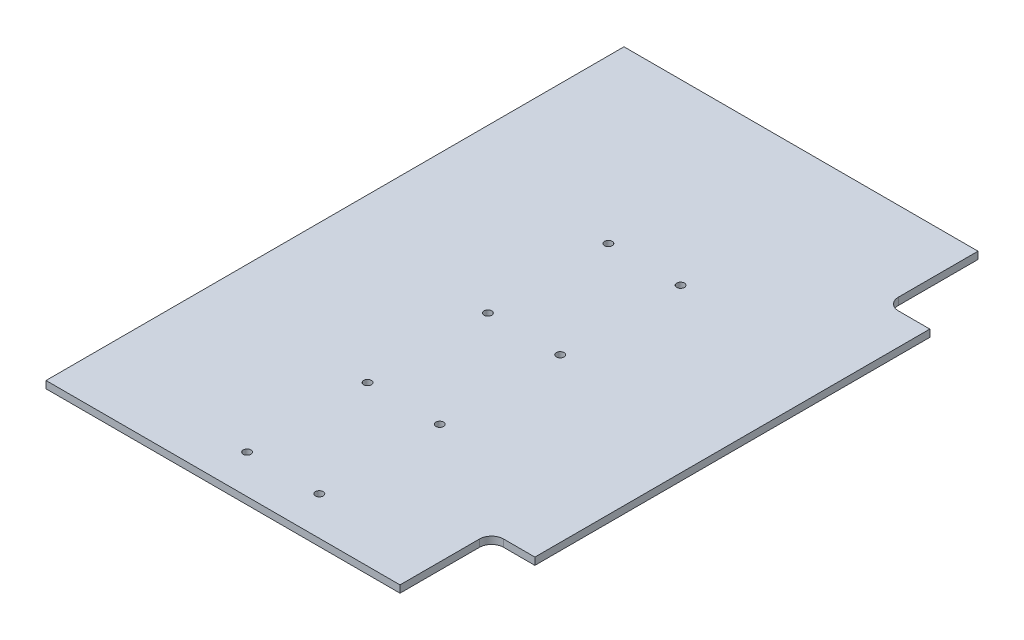
from build123d import *

# Parameters (mm, degrees)
SKETCH1_W           = 165
SKETCH1_H           = 240
BOSS_EXTRUDE1_DEPTH = 3
SKETCH3_R           = 1.6
CUT_EXTRUDE2_DEPTH  = 11
SKETCH2_W           = 18
SKETCH2_H           = 38
CUT_EXTRUDE1_DEPTH  = 11
FILLET1_R           = 5


with BuildPart() as part:
    # Sketch1 → Boss-Extrude1 (new body)
    with BuildSketch(Plane(origin=(0, 0, 0), x_dir=(1, 0, 0), z_dir=(0, 1, 0))):
        Rectangle(SKETCH1_W, SKETCH1_H)
    extrude(amount=BOSS_EXTRUDE1_DEPTH)

    # Sketch3 → Cut-Extrude2 (cut)
    with BuildSketch(Plane(origin=(0, 3, 0), x_dir=(1, 0, 0), z_dir=(0, 1, 0))):
        with Locations((15, 46)):
            Circle(SKETCH3_R)
        with Locations((-15, 46)):
            Circle(SKETCH3_R)
        with Locations((15, -4)):
            Circle(SKETCH3_R)
        with Locations((-15, -4)):
            Circle(SKETCH3_R)
        with Locations((15, -54)):
            Circle(SKETCH3_R)
        with Locations((-15, -54)):
            Circle(SKETCH3_R)
        with Locations((15, -104)):
            Circle(SKETCH3_R)
        with Locations((-15, -104)):
            Circle(SKETCH3_R)
    extrude(amount=-CUT_EXTRUDE2_DEPTH, mode=Mode.SUBTRACT)

    # Sketch2 → Cut-Extrude1 (cut)
    with BuildSketch(Plane(origin=(0, 3, 0), x_dir=(1, 0, 0), z_dir=(0, 1, 0))):
        with Locations((73.5, 101)):
            Rectangle(SKETCH2_W, SKETCH2_H)
        with Locations((73.5, -101)):
            Rectangle(SKETCH2_W, SKETCH2_H)
    extrude(amount=-CUT_EXTRUDE1_DEPTH, mode=Mode.SUBTRACT)

    # Fillet1
    fillet1_edges = [part.edges().sort_by_distance(p)[0] for p in [
        (64.5, 1.5, -82),
        (64.5, 1.5, 82),
    ]]
    fillet(fillet1_edges, radius=FILLET1_R)


solid = part.part
